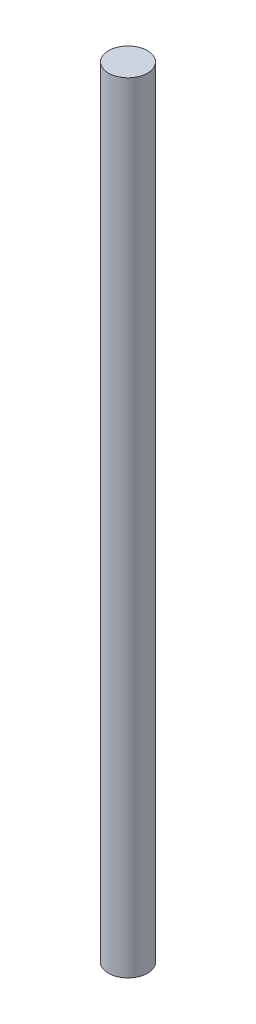
from build123d import *

# Parameters (mm, degrees)
SKETCH1_R           = 0.25
BOSS_EXTRUDE1_DEPTH = 0.75
SKETCH2_R           = 0.25
BOSS_EXTRUDE2_DEPTH = 4.25
SKETCH3_R           = 0.25
BOSS_EXTRUDE3_DEPTH = 4.25


with BuildPart() as part:
    # Sketch1 → Boss-Extrude1 (new body, symmetric)
    with BuildSketch(Plane(origin=(0, 0, 0), x_dir=(1, 0, 0), z_dir=(0, 1, 0))):
        Circle(SKETCH1_R)
    extrude(amount=BOSS_EXTRUDE1_DEPTH, both=True)

    # Sketch2 → Boss-Extrude2 (add)
    with BuildSketch(Plane(origin=(0, 0.75, 0), x_dir=(1, 0, 0), z_dir=(0, 1, 0))):
        Circle(SKETCH2_R)
    extrude(amount=BOSS_EXTRUDE2_DEPTH)

    # Sketch3 → Boss-Extrude3 (add)
    with BuildSketch(Plane.XZ.offset(0.75)):
        Circle(SKETCH3_R)
    extrude(amount=BOSS_EXTRUDE3_DEPTH)


solid = part.part
